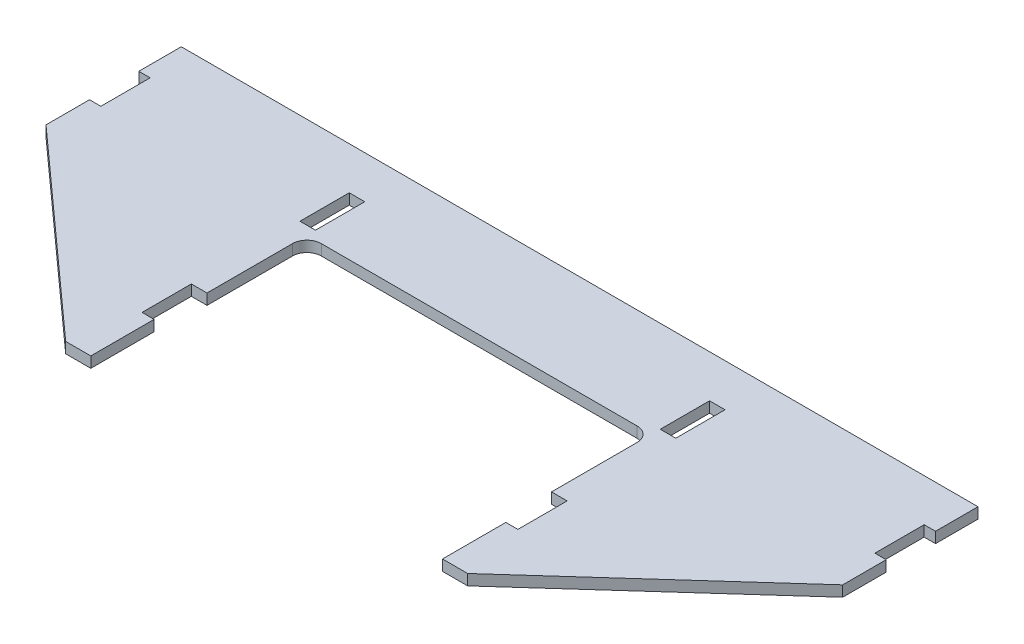
from build123d import *

# Parameters (mm, degrees)
SKETCH1_W           = 355.6
SKETCH1_H           = 58.42
BOSS_EXTRUDE1_DEPTH = 4.7625
BOSS_EXTRUDE2_DEPTH = 4.7625
FILLET1_R           = 3.175
SKETCH3_W           = 6.858
SKETCH3_H           = 21.806929344
SKETCH3_W_2         = 6.35
SKETCH3_H_2         = 21.298929344
CUT_EXTRUDE1_DEPTH  = 209.73467472
SKETCH4_W           = 1.5875
SKETCH4_H           = 18.796
CUT_EXTRUDE2_DEPTH  = 209.73467472
SKETCH5_W           = 1.5875
SKETCH5_H           = 28.002862447
CUT_EXTRUDE3_DEPTH  = 208.38411122
SKETCH6_W           = 0.3175
SKETCH6_H           = 21.806929344
BOSS_EXTRUDE3_DEPTH = 4.7625
SKETCH7_W           = 0.3175
SKETCH7_H           = 21.806929344
CUT_EXTRUDE4_DEPTH  = 208.38411122
SKETCH8_W           = 152.4
SKETCH8_H           = 17.145
CUT_EXTRUDE5_DEPTH  = 208.38411122
FILLET2_R           = 6.35


with BuildPart() as part:
    # Sketch1 → Boss-Extrude1 (new body)
    with BuildSketch(Plane(origin=(0, 0, 0), x_dir=(1, 0, 0), z_dir=(0, 1, 0))):
        Rectangle(SKETCH1_W, SKETCH1_H)
    extrude(amount=BOSS_EXTRUDE1_DEPTH)

    # Sketch2 → Boss-Extrude2 (add)
    with BuildSketch(Plane(origin=(0, 4.7625, 0), x_dir=(1, 0, 0), z_dir=(0, 1, 0))):
        Polygon((177.8, -29.21), (88.9, -109.245791791), (76.2, -109.245791791), (76.2, -29.21), align=None)
        Polygon((-177.8, -29.21), (-88.9, -109.245791791), (-76.2, -109.245791791), (-76.2, -29.21), align=None)
    extrude(amount=-BOSS_EXTRUDE2_DEPTH)

    # Fillet1
    fillet1_edges = [part.edges().sort_by_distance(p)[0] for p in [
        (-76.2, 2.38125, 29.21),
        (76.2, 2.38125, 29.21),
    ]]
    fillet(fillet1_edges, radius=FILLET1_R)

    # Sketch3 → Cut-Extrude1 (cut, through all)
    with BuildSketch(Plane(origin=(0, 0, 0), x_dir=(-1, 0, 0), z_dir=(0, -1, 0))):
        with Locations((-174.625, -0.489464672)):
            Rectangle(SKETCH3_W, SKETCH3_H)
        with Locations((-174.625, -0.489464672)):
            Rectangle(SKETCH3_W_2, SKETCH3_H_2, mode=Mode.SUBTRACT)
        with Locations((-79.375, -0.489464672)):
            Rectangle(SKETCH3_W, SKETCH3_H)
        with Locations((-79.375, -0.489464672)):
            Rectangle(SKETCH3_W_2, SKETCH3_H_2, mode=Mode.SUBTRACT)
        with Locations((-79.375, -70.339464672)):
            Rectangle(SKETCH3_W, SKETCH3_H)
        with Locations((-79.375, -70.339464672)):
            Rectangle(SKETCH3_W_2, SKETCH3_H_2, mode=Mode.SUBTRACT)
        with Locations((79.375, -70.339464672)):
            Rectangle(SKETCH3_W, SKETCH3_H)
        with Locations((79.375, -70.339464672)):
            Rectangle(SKETCH3_W_2, SKETCH3_H_2, mode=Mode.SUBTRACT)
        with Locations((79.375, -0.489464672)):
            Rectangle(SKETCH3_W, SKETCH3_H)
        with Locations((79.375, -0.489464672)):
            Rectangle(SKETCH3_W_2, SKETCH3_H_2, mode=Mode.SUBTRACT)
        with Locations((174.625, -0.489464672)):
            Rectangle(SKETCH3_W, SKETCH3_H)
        with Locations((174.625, -0.489464672)):
            Rectangle(SKETCH3_W_2, SKETCH3_H_2, mode=Mode.SUBTRACT)
    extrude(amount=-CUT_EXTRUDE1_DEPTH, mode=Mode.SUBTRACT)


with BuildPart() as body_2:
    # of the pieces the cut leaves, the one that is kept (cut_extrude1_keep)
    add(part.part.solids().sort_by_distance((76.2, 0, 109.245791791))[0])

    # Sketch4 → Cut-Extrude2 (cut, through all)
    with BuildSketch(Plane(origin=(0, 4.7625, 0), x_dir=(1, 0, 0), z_dir=(0, 1, 0))):
        Polygon((177.8, -11.392929344), (176.2125, -11.392929344), (176.2125, -30.639210568), (177.8, -29.21), align=None)
        with Locations((177.00625, 19.812)):
            Rectangle(SKETCH4_W, SKETCH4_H)
        with Locations((-177.00625, 19.812)):
            Rectangle(SKETCH4_W, SKETCH4_H)
        Polygon((-176.2125, -30.639210568), (-176.2125, -11.392929344), (-177.8, -11.392929344), (-177.8, -29.21), align=None)
    extrude(amount=-CUT_EXTRUDE2_DEPTH, mode=Mode.SUBTRACT)

    # Sketch5 → Cut-Extrude3 (cut, through all)
    with BuildSketch(Plane(origin=(0, 4.7625, 0), x_dir=(1, 0, 0), z_dir=(0, 1, 0))):
        with Locations((-76.99375, -95.244360567)):
            Rectangle(SKETCH5_W, SKETCH5_H)
        with Locations((76.99375, -95.244360567)):
            Rectangle(SKETCH5_W, SKETCH5_H)
    extrude(amount=-CUT_EXTRUDE3_DEPTH, mode=Mode.SUBTRACT)

    # Sketch6 → Boss-Extrude3 (add)
    with BuildSketch(Plane.XZ):
        with Locations((-76.10475, 0.489464672)):
            Rectangle(SKETCH6_W, SKETCH6_H)
        with Locations((76.10475, 0.489464672)):
            Rectangle(SKETCH6_W, SKETCH6_H)
    extrude(amount=-BOSS_EXTRUDE3_DEPTH)

    # Sketch7 → Cut-Extrude4 (cut, through all)
    with BuildSketch(Plane.XZ):
        with Locations((-82.96275, 0.489464672)):
            Rectangle(SKETCH7_W, SKETCH7_H)
        with Locations((-82.96275, 70.339464672)):
            Rectangle(SKETCH7_W, SKETCH7_H)
        with Locations((82.96275, 70.339464672)):
            Rectangle(SKETCH7_W, SKETCH7_H)
        with Locations((82.96275, 0.489464672)):
            Rectangle(SKETCH7_W, SKETCH7_H)
    extrude(amount=-CUT_EXTRUDE4_DEPTH, mode=Mode.SUBTRACT)

    # Sketch8 → Cut-Extrude5 (cut, through all)
    with BuildSketch(Plane(origin=(0, 4.7625, 0), x_dir=(1, 0, 0), z_dir=(0, 1, 0))):
        with Locations((0, -23.8125)):
            Rectangle(SKETCH8_W, SKETCH8_H)
    extrude(amount=-CUT_EXTRUDE5_DEPTH, mode=Mode.SUBTRACT)

    # Fillet2
    fillet2_edges = [body_2.edges().sort_by_distance(p)[0] for p in [
        (76.2, 2.38125, 15.24),
        (-76.2, 2.38125, 15.24),
    ]]
    fillet(fillet2_edges, radius=FILLET2_R)


solid = body_2.part
